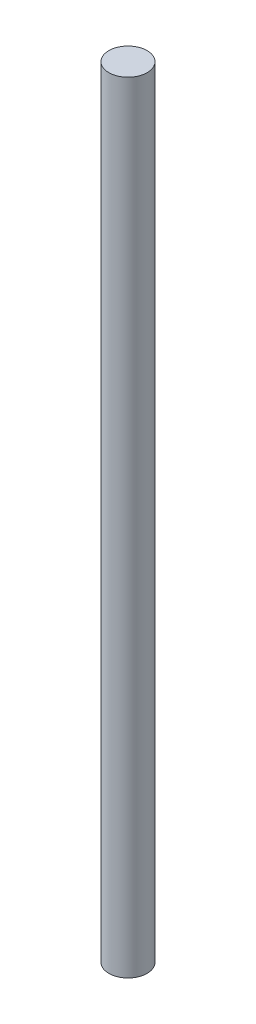
from build123d import *

# Parameters (mm, degrees)
SKETCH1_R           = 2.5
BOSS_EXTRUDE1_DEPTH = 102


with BuildPart() as part:
    # Sketch1 → Boss-Extrude1 (new body)
    with BuildSketch(Plane(origin=(0, 0, 0), x_dir=(1, 0, 0), z_dir=(0, 1, 0))):
        Circle(SKETCH1_R)
    extrude(amount=BOSS_EXTRUDE1_DEPTH)


solid = part.part
